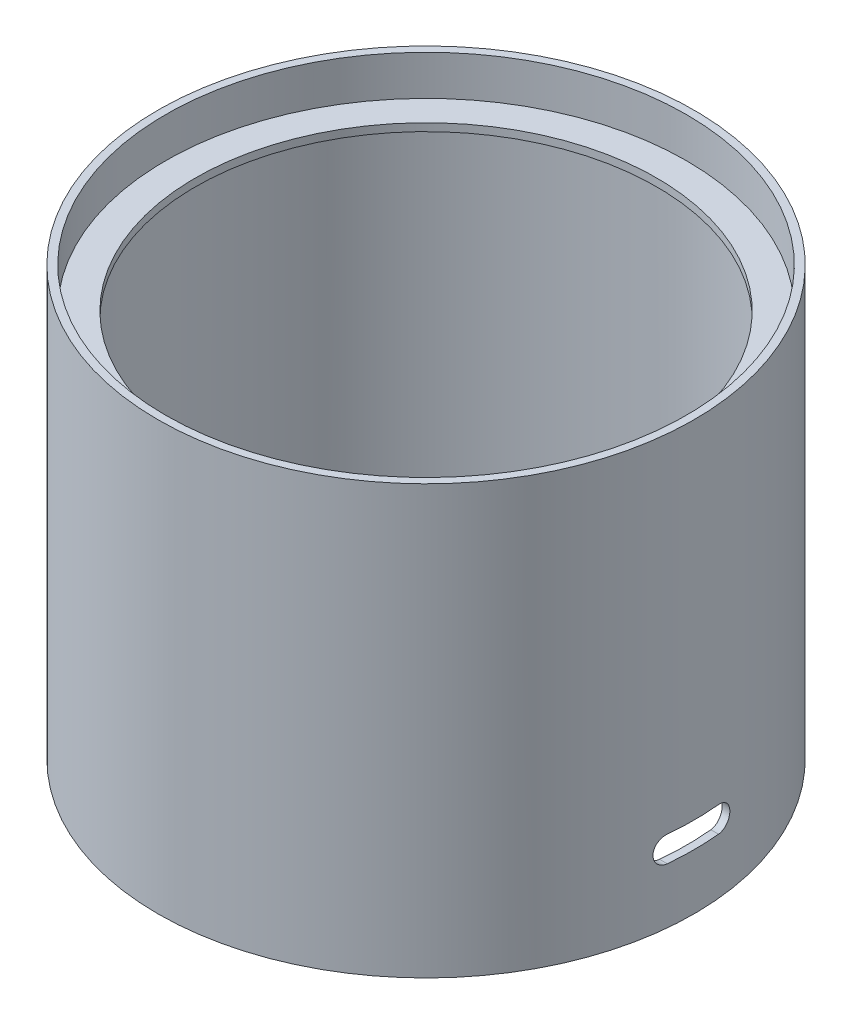
from build123d import *

# Parameters (mm, degrees)
SKETCH1_R           = 104.625
SKETCH1_R_2         = 101.625
BOSS_EXTRUDE1_DEPTH = 83.5
CUT_EXTRUDE1_REACH  = 106.625
SKETCH2_W           = 40
SKETCH2_H           = 50
CUT_EXTRUDE2_REACH  = 106.625
SKETCH4_R           = 101.625
SKETCH4_R_2         = 90
BOSS_EXTRUDE2_DEPTH = 3
FILLET1_R           = 10


with BuildPart() as part:
    # Sketch1 → Boss-Extrude1 (new body, symmetric)
    with BuildSketch(Plane(origin=(0, 0, 0), x_dir=(1, 0, 0), z_dir=(0, 1, 0))):
        Circle(SKETCH1_R)
        Circle(SKETCH1_R_2, mode=Mode.SUBTRACT)
    extrude(amount=BOSS_EXTRUDE1_DEPTH, both=True)

    # Sketch2 → Cut-Extrude1 (cut, up to next)
    with BuildSketch(Plane.XY, mode=Mode.PRIVATE) as cut_extrude1_sk1:
        with Locations((0, -58.5)):
            Rectangle(SKETCH2_W, SKETCH2_H)
    cut_extrude1_tool1 = extrude(cut_extrude1_sk1.sketch, amount=-CUT_EXTRUDE1_REACH, mode=Mode.PRIVATE) & part.part
    add(cut_extrude1_tool1.solids().sort_by_distance((0, -58.5, 0))[0], mode=Mode.SUBTRACT)

    # Sketch3 → Cut-Extrude2 (cut, up to next)
    with BuildSketch(Plane(origin=(0, 0, 0), x_dir=(0, 0, -1), z_dir=(1, 0, 0)), mode=Mode.PRIVATE) as cut_extrude2_sk1:
        with BuildLine():
            Line((-10, -51.809036258), (10, -51.809036258))
            ThreePointArc((10, -51.809036258), (15, -56.809036258), (10, -61.809036258))
            Line((10, -61.809036258), (-10, -61.809036258))
            ThreePointArc((-10, -61.809036258), (-15, -56.809036258), (-10, -51.809036258))
        make_face()
    cut_extrude2_tool1 = extrude(cut_extrude2_sk1.sketch, amount=CUT_EXTRUDE2_REACH, mode=Mode.PRIVATE) & part.part
    add(cut_extrude2_tool1.solids().sort_by_distance((0, -56.809036, 0))[0], mode=Mode.SUBTRACT)

    # Sketch4 → Boss-Extrude2 (add)
    with BuildSketch(Plane(origin=(0, 67.9, 0), x_dir=(1, 0, 0), z_dir=(0, 1, 0))):
        Circle(SKETCH4_R)
        Circle(SKETCH4_R_2, mode=Mode.SUBTRACT)
    extrude(amount=-BOSS_EXTRUDE2_DEPTH)

    # Fillet1
    fillet1_edges = [part.edges().sort_by_distance(p)[0] for p in [
        (20, -33.5, -101.166583758),
        (-20, -33.5, -101.166583758),
    ]]
    fillet(fillet1_edges, radius=FILLET1_R)


solid = part.part
